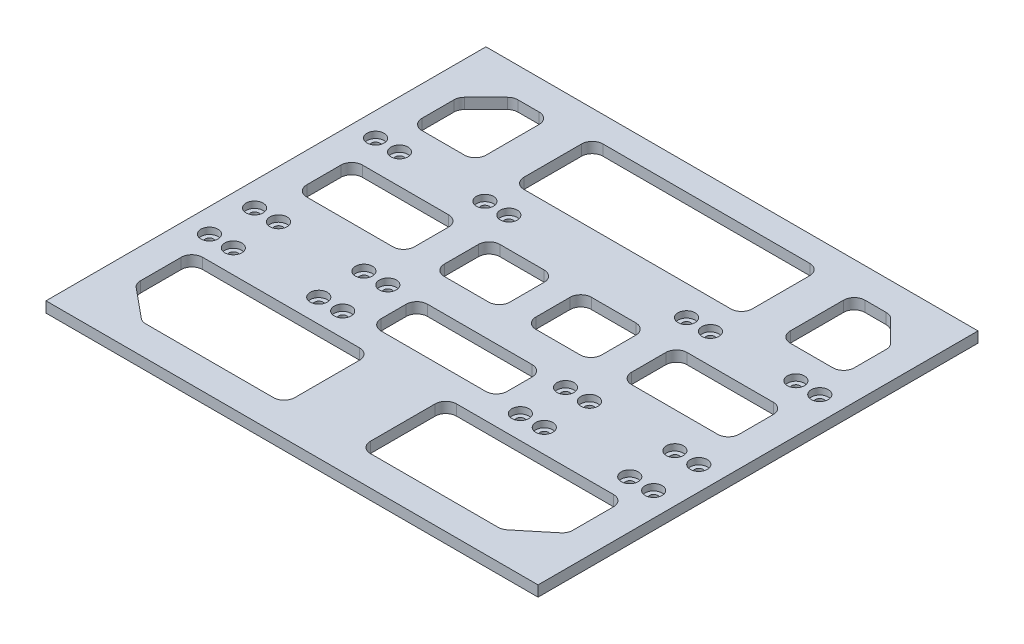
from build123d import *

# Parameters (mm, degrees)
SKETCH1_W           = 115
SKETCH1_H           = 103
BOSS_EXTRUDE1_DEPTH = 2.5
SKETCH2_R           = 1
CUT_EXTRUDE1_DEPTH  = 10
SKETCH3_W           = 103
SKETCH3_H           = 2.5
BOSS_EXTRUDE2_DEPTH = 0.1
SKETCH4_W           = 103
SKETCH4_H           = 2.5
BOSS_EXTRUDE3_DEPTH = 0.1
SKETCH5_R           = 1
CUT_EXTRUDE2_DEPTH  = 10
CUT_EXTRUDE3_DEPTH  = 10
SKETCH7_R           = 2
CUT_EXTRUDE4_DEPTH  = 1.5


with BuildPart() as part:
    # Sketch1 → Boss-Extrude1 (new body)
    with BuildSketch(Plane(origin=(0, 0, 0), x_dir=(1, 0, 0), z_dir=(0, 1, 0))):
        Rectangle(SKETCH1_W, SKETCH1_H)
    extrude(amount=BOSS_EXTRUDE1_DEPTH)

    # Sketch2 → Cut-Extrude1 (cut)
    with BuildSketch(Plane.XZ):
        with Locations((-52, -20.06)):
            Circle(SKETCH2_R)
        with Locations((-52, 8.27)):
            Circle(SKETCH2_R)
        with Locations((-52, 18.84)):
            Circle(SKETCH2_R)
        with Locations((52, -20.06)):
            Circle(SKETCH2_R)
        with Locations((52, 8.27)):
            Circle(SKETCH2_R)
        with Locations((52, 18.84)):
            Circle(SKETCH2_R)
        with Locations((-46.4, 18.84)):
            Circle(SKETCH2_R)
        with Locations((-46.4, -20.06)):
            Circle(SKETCH2_R)
        with Locations((-46.4, 8.27)):
            Circle(SKETCH2_R)
        with Locations((46.4, -20.06)):
            Circle(SKETCH2_R)
        with Locations((46.4, 8.27)):
            Circle(SKETCH2_R)
        with Locations((46.4, 18.84)):
            Circle(SKETCH2_R)
    extrude(amount=-CUT_EXTRUDE1_DEPTH, mode=Mode.SUBTRACT)

    # Sketch3 → Boss-Extrude2 (add)
    with BuildSketch(Plane.ZY.offset(57.5)):
        with Locations((0, 1.25)):
            Rectangle(SKETCH3_W, SKETCH3_H)
    extrude(amount=BOSS_EXTRUDE2_DEPTH)

    # Sketch4 → Boss-Extrude3 (add)
    with BuildSketch(Plane(origin=(57.5, 0, 0), x_dir=(0, 0, -1), z_dir=(1, 0, 0))):
        with Locations((0, 1.25)):
            Rectangle(SKETCH4_W, SKETCH4_H)
    extrude(amount=BOSS_EXTRUDE3_DEPTH)

    # Sketch5 → Cut-Extrude2 (cut)
    with BuildSketch(Plane(origin=(0, 2.5, 0), x_dir=(1, 0, 0), z_dir=(0, 1, 0))):
        with Locations((-26.4, 20.06)):
            Circle(SKETCH5_R)
        with Locations((-26.4, -8.27)):
            Circle(SKETCH5_R)
        with Locations((-26.4, -18.84)):
            Circle(SKETCH5_R)
        with Locations((-20.8, 20.06)):
            Circle(SKETCH5_R)
        with Locations((-20.8, -8.27)):
            Circle(SKETCH5_R)
        with Locations((-20.8, -18.84)):
            Circle(SKETCH5_R)
        with Locations((26.4, -18.84)):
            Circle(SKETCH5_R)
        with Locations((20.8, -18.84)):
            Circle(SKETCH5_R)
        with Locations((26.4, -8.27)):
            Circle(SKETCH5_R)
        with Locations((20.8, -8.27)):
            Circle(SKETCH5_R)
        with Locations((26.4, 20.06)):
            Circle(SKETCH5_R)
        with Locations((20.8, 20.06)):
            Circle(SKETCH5_R)
    extrude(amount=-CUT_EXTRUDE2_DEPTH, mode=Mode.SUBTRACT)

    # Sketch6 → Cut-Extrude3 (cut)
    with BuildSketch(Plane(origin=(0, 2.5, 0), x_dir=(1, 0, 0), z_dir=(0, 1, 0))):
        with BuildLine():
            Line((-44.876180251, 43.767766953), (-49.867766953, 38.776180251))
            ThreePointArc((-49.867766953, 38.776180251), (-50.409698831, 37.965121879), (-50.6, 37.008413298))
            Line((-50.6, 37.008413298), (-50.6, 29.525557041))
            ThreePointArc((-50.6, 29.525557041), (-49.867766953, 27.757790088), (-48.1, 27.025557041))
            Line((-48.1, 27.025557041), (-38.125738345, 27.025557041))
            ThreePointArc((-38.125738345, 27.025557041), (-36.357971392, 27.757790088), (-35.625738345, 29.525557041))
            Line((-35.625738345, 29.525557041), (-35.625738345, 42))
            ThreePointArc((-35.625738345, 42), (-36.357971392, 43.767766953), (-38.125738345, 44.5))
            Line((-38.125738345, 44.5), (-43.108413298, 44.5))
            ThreePointArc((-43.108413298, 44.5), (-44.065121879, 44.309698831), (-44.876180251, 43.767766953))
        make_face()
        with BuildLine():
            Line((-24.211357367, 45.5), (24.211357367, 45.5))
            ThreePointArc((24.211357367, 45.5), (25.97912432, 44.767766953), (26.711357367, 43))
            Line((26.711357367, 43), (26.711357367, 29.525557041))
            ThreePointArc((26.711357367, 29.525557041), (25.97912432, 27.757790088), (24.211357367, 27.025557041))
            Line((24.211357367, 27.025557041), (-24.211357367, 27.025557041))
            ThreePointArc((-24.211357367, 27.025557041), (-25.97912432, 27.757790088), (-26.711357367, 29.525557041))
            Line((-26.711357367, 29.525557041), (-26.711357367, 43))
            ThreePointArc((-26.711357367, 43), (-25.97912432, 44.767766953), (-24.211357367, 45.5))
        make_face()
        with BuildLine():
            Line((-49.688762468, -38.300141018), (-42.84856017, -43.930241908))
            ThreePointArc((-42.84856017, -43.930241908), (-42.103715717, -44.353253574), (-41.259797703, -44.5))
            Line((-41.259797703, -44.5), (-11.348843163, -44.5))
            ThreePointArc((-11.348843163, -44.5), (-9.58107621, -43.767766953), (-8.848843163, -42))
            Line((-8.848843163, -42), (-8.848843163, -26.836258094))
            ThreePointArc((-8.848843163, -26.836258094), (-9.58107621, -25.068491141), (-11.348843163, -24.336258094))
            Line((-11.348843163, -24.336258094), (-48.1, -24.336258094))
            ThreePointArc((-48.1, -24.336258094), (-49.867766953, -25.068491141), (-50.6, -26.836258094))
            Line((-50.6, -26.836258094), (-50.6, -36.369899111))
            ThreePointArc((-50.6, -36.369899111), (-50.360741711, -37.43716052), (-49.688762468, -38.300141018))
        make_face()
        with BuildLine():
            Line((-48.1, 0.056382832), (-27.927103688, 0.056382832))
            ThreePointArc((-27.927103688, 0.056382832), (-26.159336735, 0.788615879), (-25.427103688, 2.556382832))
            Line((-25.427103688, 2.556382832), (-25.427103688, 10.569015944))
            ThreePointArc((-25.427103688, 10.569015944), (-26.159336735, 12.336782897), (-27.927103688, 13.069015944))
            Line((-27.927103688, 13.069015944), (-48.1, 13.069015944))
            ThreePointArc((-48.1, 13.069015944), (-49.867766953, 12.336782897), (-50.6, 10.569015944))
            Line((-50.6, 10.569015944), (-50.6, 2.556382832))
            ThreePointArc((-50.6, 2.556382832), (-49.867766953, 0.788615879), (-48.1, 0.056382832))
        make_face()
        with BuildLine():
            Line((-15.91791754, 0.056382832), (-5.533746838, 0.056382832))
            ThreePointArc((-5.533746838, 0.056382832), (-3.765979885, 0.788615879), (-3.033746838, 2.556382832))
            Line((-3.033746838, 2.556382832), (-3.033746838, 10.569015944))
            ThreePointArc((-3.033746838, 10.569015944), (-3.765979885, 12.336782897), (-5.533746838, 13.069015944))
            Line((-5.533746838, 13.069015944), (-15.91791754, 13.069015944))
            ThreePointArc((-15.91791754, 13.069015944), (-17.685684493, 12.336782897), (-18.41791754, 10.569015944))
            Line((-18.41791754, 10.569015944), (-18.41791754, 2.556382832))
            ThreePointArc((-18.41791754, 2.556382832), (-17.685684493, 0.788615879), (-15.91791754, 0.056382832))
        make_face()
        with BuildLine():
            Line((41.259797703, -44.5), (11.348843163, -44.5))
            ThreePointArc((11.348843163, -44.5), (9.58107621, -43.767766953), (8.848843163, -42))
            Line((8.848843163, -42), (8.848843163, -26.836258094))
            ThreePointArc((8.848843163, -26.836258094), (9.58107621, -25.068491141), (11.348843163, -24.336258094))
            Line((11.348843163, -24.336258094), (48.1, -24.336258094))
            ThreePointArc((48.1, -24.336258094), (49.867766953, -25.068491141), (50.6, -26.836258094))
            Line((50.6, -26.836258094), (50.6, -36.369899111))
            ThreePointArc((50.6, -36.369899111), (50.360741711, -37.43716052), (49.688762468, -38.300141018))
            Line((49.688762468, -38.300141018), (42.84856017, -43.930241908))
            ThreePointArc((42.84856017, -43.930241908), (42.103715717, -44.353253574), (41.259797703, -44.5))
        make_face()
        with BuildLine():
            Line((-12.250112184, -18.396518995), (12.250112184, -18.396518995))
            ThreePointArc((12.250112184, -18.396518995), (14.017879137, -17.664285948), (14.750112184, -15.896518995))
            Line((14.750112184, -15.896518995), (14.750112184, -10.023618282))
            ThreePointArc((14.750112184, -10.023618282), (14.017879137, -8.255851329), (12.250112184, -7.523618282))
            Line((12.250112184, -7.523618282), (-12.250112184, -7.523618282))
            ThreePointArc((-12.250112184, -7.523618282), (-14.017879137, -8.255851329), (-14.750112184, -10.023618282))
            Line((-14.750112184, -10.023618282), (-14.750112184, -15.896518995))
            ThreePointArc((-14.750112184, -15.896518995), (-14.017879137, -17.664285948), (-12.250112184, -18.396518995))
        make_face()
        with BuildLine():
            Line((3.033746838, 2.556382832), (3.033746838, 10.569015944))
            ThreePointArc((3.033746838, 10.569015944), (3.765979885, 12.336782897), (5.533746838, 13.069015944))
            Line((5.533746838, 13.069015944), (15.91791754, 13.069015944))
            ThreePointArc((15.91791754, 13.069015944), (17.685684493, 12.336782897), (18.41791754, 10.569015944))
            Line((18.41791754, 10.569015944), (18.41791754, 2.556382832))
            ThreePointArc((18.41791754, 2.556382832), (17.685684493, 0.788615879), (15.91791754, 0.056382832))
            Line((15.91791754, 0.056382832), (5.533746838, 0.056382832))
            ThreePointArc((5.533746838, 0.056382832), (3.765979885, 0.788615879), (3.033746838, 2.556382832))
        make_face()
        with BuildLine():
            Line((48.1, 0.056382832), (27.927103688, 0.056382832))
            ThreePointArc((27.927103688, 0.056382832), (26.159336735, 0.788615879), (25.427103688, 2.556382832))
            Line((25.427103688, 2.556382832), (25.427103688, 10.569015944))
            ThreePointArc((25.427103688, 10.569015944), (26.159336735, 12.336782897), (27.927103688, 13.069015944))
            Line((27.927103688, 13.069015944), (48.1, 13.069015944))
            ThreePointArc((48.1, 13.069015944), (49.867766953, 12.336782897), (50.6, 10.569015944))
            Line((50.6, 10.569015944), (50.6, 2.556382832))
            ThreePointArc((50.6, 2.556382832), (49.867766953, 0.788615879), (48.1, 0.056382832))
        make_face()
        with BuildLine():
            Line((48.1, 27.025557041), (38.125738345, 27.025557041))
            ThreePointArc((38.125738345, 27.025557041), (36.357971392, 27.757790088), (35.625738345, 29.525557041))
            Line((35.625738345, 29.525557041), (35.625738345, 42))
            ThreePointArc((35.625738345, 42), (36.357971392, 43.767766953), (38.125738345, 44.5))
            Line((38.125738345, 44.5), (43.108413298, 44.5))
            ThreePointArc((43.108413298, 44.5), (44.065121879, 44.309698831), (44.876180251, 43.767766953))
            Line((44.876180251, 43.767766953), (49.867766953, 38.776180251))
            ThreePointArc((49.867766953, 38.776180251), (50.409698831, 37.965121879), (50.6, 37.008413298))
            Line((50.6, 37.008413298), (50.6, 29.525557041))
            ThreePointArc((50.6, 29.525557041), (49.867766953, 27.757790088), (48.1, 27.025557041))
        make_face()
    extrude(amount=-CUT_EXTRUDE3_DEPTH, mode=Mode.SUBTRACT)

    # Sketch7 → Cut-Extrude4 (cut)
    with BuildSketch(Plane(origin=(0, 2.5, 0), x_dir=(1, 0, 0), z_dir=(0, 1, 0))):
        with Locations((-52, 20.06)):
            Circle(SKETCH7_R)
        with Locations((-46.4, 20.06)):
            Circle(SKETCH7_R)
        with Locations((-26.4, 20.06)):
            Circle(SKETCH7_R)
        with Locations((-20.8, 20.06)):
            Circle(SKETCH7_R)
        with Locations((-52, -8.27)):
            Circle(SKETCH7_R)
        with Locations((-46.4, -8.27)):
            Circle(SKETCH7_R)
        with Locations((-52, -18.84)):
            Circle(SKETCH7_R)
        with Locations((-46.4, -18.84)):
            Circle(SKETCH7_R)
        with Locations((-26.4, -18.84)):
            Circle(SKETCH7_R)
        with Locations((-20.8, -18.84)):
            Circle(SKETCH7_R)
        with Locations((-20.8, -8.27)):
            Circle(SKETCH7_R)
        with Locations((-26.4, -8.27)):
            Circle(SKETCH7_R)
        with Locations((20.8, -18.84)):
            Circle(SKETCH7_R)
        with Locations((26.4, -18.84)):
            Circle(SKETCH7_R)
        with Locations((20.8, -8.27)):
            Circle(SKETCH7_R)
        with Locations((26.4, -8.27)):
            Circle(SKETCH7_R)
        with Locations((46.4, -18.84)):
            Circle(SKETCH7_R)
        with Locations((52, -18.84)):
            Circle(SKETCH7_R)
        with Locations((46.4, -8.27)):
            Circle(SKETCH7_R)
        with Locations((52, -8.27)):
            Circle(SKETCH7_R)
        with Locations((20.8, 20.06)):
            Circle(SKETCH7_R)
        with Locations((26.4, 20.06)):
            Circle(SKETCH7_R)
        with Locations((52, 20.06)):
            Circle(SKETCH7_R)
        with Locations((46.4, 20.06)):
            Circle(SKETCH7_R)
    extrude(amount=-CUT_EXTRUDE4_DEPTH, mode=Mode.SUBTRACT)


solid = part.part
